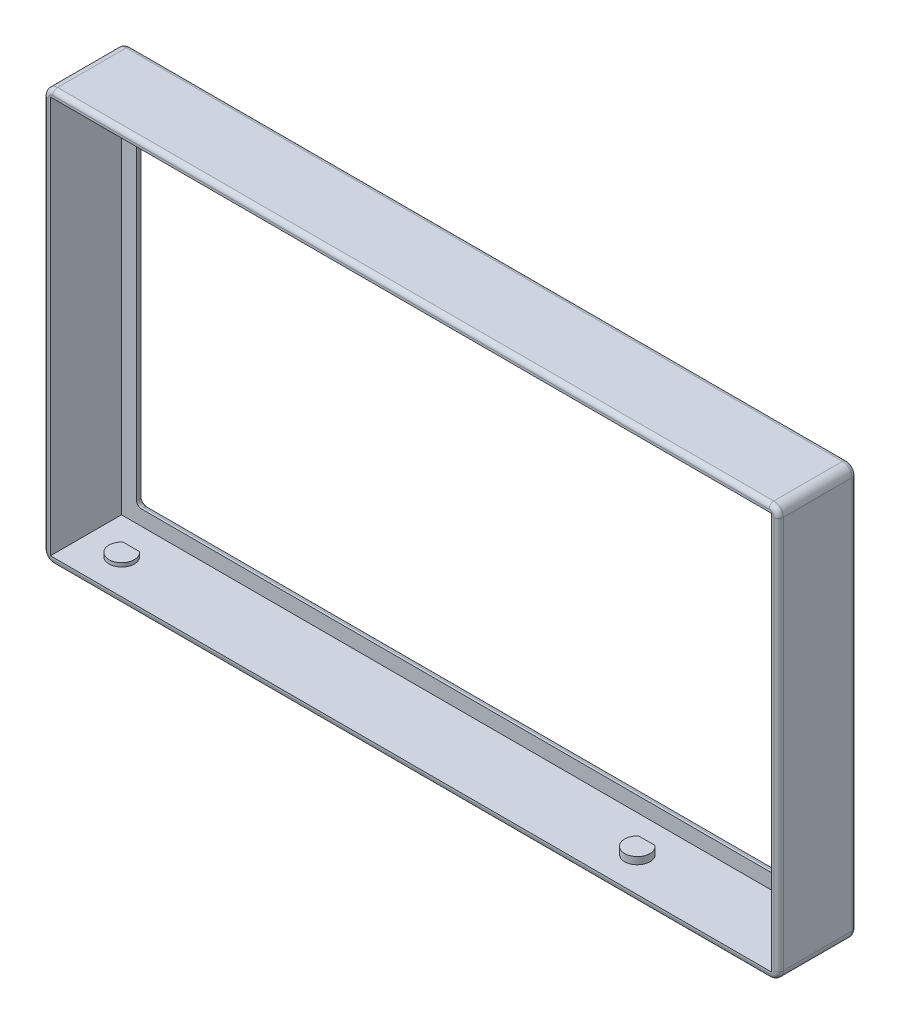
from build123d import *

# Parameters (mm, degrees)
SKETCH1_W           = 155.4
SKETCH1_H           = 86.98
SKETCH1_W_2         = 146
SKETCH1_H_2         = 77.58
BOSS_EXTRUDE2_DEPTH = 1.5
SKETCH1_4_W         = 155.4
SKETCH1_4_H         = 86.98
SKETCH1_4_W_2       = 152.4
SKETCH1_4_H_2       = 83.98
BOSS_EXTRUDE3_DEPTH = 15
FILLET1_R           = 2
FILLET2_R           = 1
FILLET3_R           = 1
BOSS_EXTRUDE4_DEPTH = 0.8
BOSS_EXTRUDE5_START = 1
BOSS_EXTRUDE5_DEPTH = 1
BOSS_EXTRUDE6_DEPTH = 1.5


with BuildPart() as part:
    # Sketch1 → Boss-Extrude2 (new body)
    with BuildSketch(Plane(origin=(0, 0, -28.222648695), x_dir=(-1, 0, 0), z_dir=(0, 0, -1))):
        with Locations((-64.074179317, 56.745922466)):
            Rectangle(SKETCH1_W, SKETCH1_H)
        with Locations((-64.074179317, 56.745922466)):
            Rectangle(SKETCH1_W_2, SKETCH1_H_2, mode=Mode.SUBTRACT)
    extrude(amount=BOSS_EXTRUDE2_DEPTH)

    # Sketch1_4 → Boss-Extrude3 (add)
    with BuildSketch(Plane(origin=(0, 0, -28.222648695), x_dir=(-1, 0, 0), z_dir=(0, 0, -1))):
        with Locations((-64.074179317, 56.745922466)):
            Rectangle(SKETCH1_4_W, SKETCH1_4_H)
        with Locations((-64.074179317, 56.745922466)):
            Rectangle(SKETCH1_4_W_2, SKETCH1_4_H_2, mode=Mode.SUBTRACT)
    extrude(amount=-BOSS_EXTRUDE3_DEPTH)

    # Fillet1
    fillet1_edges = [part.edges().sort_by_distance(p)[0] for p in [
        (141.774179317, 100.235922466, -21.472648695),
        (-13.625820683, 100.235922466, -21.472648695),
        (-13.625820683, 13.255922466, -21.472648695),
        (141.774179317, 13.255922466, -21.472648695),
    ]]
    fillet(fillet1_edges, radius=FILLET1_R)

    # Fillet2
    fillet2_edges = [part.edges().sort_by_distance(p)[0] for p in [
        (-8.925820683, 56.745922466, -29.722648695),
        (64.074179317, 95.535922466, -29.722648695),
        (64.074179317, 17.955922466, -29.722648695),
        (141.188392879, 99.650136028, -29.722648695),
        (64.074179317, 100.235922466, -29.722648695),
        (-13.040034245, 99.650136028, -29.722648695),
        (-13.625820683, 56.745922466, -29.722648695),
        (-13.040034245, 13.841708903, -29.722648695),
        (64.074179317, 13.255922466, -29.722648695),
        (141.188392879, 13.841708903, -29.722648695),
        (141.774179317, 56.745922466, -29.722648695),
        (137.074179317, 56.745922466, -29.722648695),
        (137.074179317, 95.535922466, -28.972648695),
        (137.074179317, 17.955922466, -28.972648695),
        (-8.925820683, 17.955922466, -28.972648695),
        (-8.925820683, 95.535922466, -28.972648695),
    ]]
    fillet(fillet2_edges, radius=FILLET2_R)

    # Fillet3
    fillet3_edges = [part.edges().sort_by_distance(p)[0] for p in [
        (141.188392879, 13.841708903, -13.222648695),
        (141.774179317, 56.745922466, -13.222648695),
        (141.188392879, 99.650136028, -13.222648695),
        (64.074179317, 100.235922466, -13.222648695),
        (-13.040034245, 99.650136028, -13.222648695),
        (-13.625820683, 56.745922466, -13.222648695),
        (-13.040034245, 13.841708903, -13.222648695),
        (64.074179317, 13.255922466, -13.222648695),
    ]]
    fillet(fillet3_edges, radius=FILLET3_R)

    # Sketch2 → Boss-Extrude4 (add)
    with BuildSketch(Plane(origin=(0, 14.755922466, 0), x_dir=(1, 0, 0), z_dir=(0, 1, 0))):
        with BuildLine():
            Line((106.324179317, 22.595795996), (102.824179317, 22.595795996))
            ThreePointArc((102.824179317, 22.595795996), (104.574179317, 17.897648695), (106.324179317, 22.595795996))
        make_face()
        with BuildLine():
            Line((-2.675820683, 22.595795996), (-6.175820683, 22.595795996))
            ThreePointArc((-6.175820683, 22.595795996), (-4.425820683, 17.897648695), (-2.675820683, 22.595795996))
        make_face()
    extrude(amount=BOSS_EXTRUDE4_DEPTH)

    # Sketch4 → Boss-Extrude5 (add)
    with BuildSketch(Plane.XZ.offset(-98.735922466).offset(BOSS_EXTRUDE5_START)):
        with BuildLine():
            ThreePointArc((134.324179317, -22.595795996), (132.574179317, -17.897648695), (130.824179317, -22.595795996))
            Line((130.824179317, -22.595795996), (134.324179317, -22.595795996))
        make_face()
        with BuildLine():
            ThreePointArc((-2.675820683, -22.595795996), (-4.425820683, -17.897648695), (-6.175820683, -22.595795996))
            Line((-6.175820683, -22.595795996), (-2.675820683, -22.595795996))
        make_face()
    extrude(amount=-BOSS_EXTRUDE5_DEPTH)

    # Sketch2_3 → Boss-Extrude6 (add)
    with BuildSketch(Plane(origin=(0, 14.755922466, 0), x_dir=(1, 0, 0), z_dir=(0, 1, 0))):
        with BuildLine():
            Line((106.324179317, 22.595795996), (102.824179317, 22.595795996))
            ThreePointArc((102.824179317, 22.595795996), (103.461890011, 18.139864796), (107.249179317, 20.572648695))
            ThreePointArc((107.249179317, 20.572648695), (107.006963216, 21.684938001), (106.324179317, 22.595795996))
        make_face()
    extrude(amount=BOSS_EXTRUDE6_DEPTH)


solid = part.part
